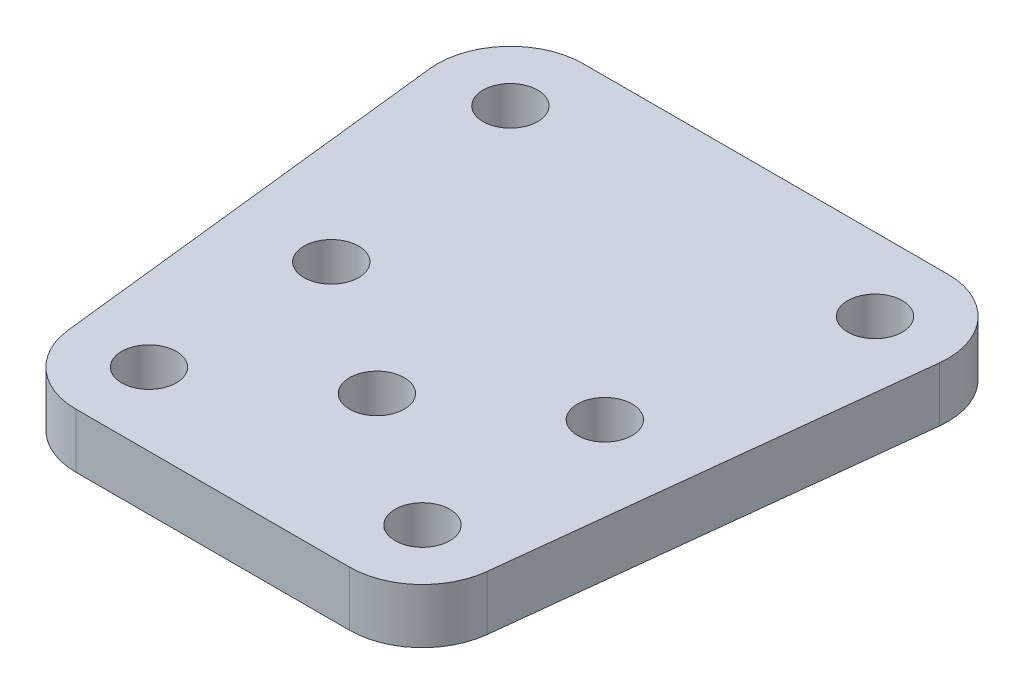
from build123d import *

# Parameters (mm, degrees)
SKETCH1_R           = 1.5
BOSS_EXTRUDE1_DEPTH = 3


with BuildPart() as part:
    # Sketch1 → Boss-Extrude1 (new body)
    with BuildSketch(Plane(origin=(0, 0, 0), x_dir=(1, 0, 0), z_dir=(0, 1, 0))):
        with BuildLine():
            Line((-10.458743839, 9.337820174), (-7.958743839, -12.982687901))
            ThreePointArc((-7.958743839, -12.982687901), (-6.649970685, -15.519142393), (-3.983600283, -16.537453462))
            Line((-3.983600283, -16.537453462), (11.016399717, -16.537453462))
            ThreePointArc((11.016399717, -16.537453462), (13.68277012, -15.519142393), (14.991543274, -12.982687901))
            Line((14.991543274, -12.982687901), (17.491543274, 9.337820174))
            ThreePointArc((17.491543274, 9.337820174), (16.498088648, 12.449425016), (13.516399717, 13.783054613))
            Line((13.516399717, 13.783054613), (-6.483600283, 13.783054613))
            ThreePointArc((-6.483600283, 13.783054613), (-9.465289213, 12.449425016), (-10.458743839, 9.337820174))
        make_face()
        with Locations((-3.983600283, -12.537453462)):
            Circle(SKETCH1_R, mode=Mode.SUBTRACT)
        with Locations((11.016399717, -12.537453462)):
            Circle(SKETCH1_R, mode=Mode.SUBTRACT)
        with Locations((3.516399717, -7.537453462)):
            Circle(SKETCH1_R, mode=Mode.SUBTRACT)
        with Locations((11.016399717, -2.537453462)):
            Circle(SKETCH1_R, mode=Mode.SUBTRACT)
        with Locations((-3.983600283, -2.537453462)):
            Circle(SKETCH1_R, mode=Mode.SUBTRACT)
        with Locations((13.516399717, 9.783054613)):
            Circle(SKETCH1_R, mode=Mode.SUBTRACT)
        with Locations((-6.483600283, 9.783054613)):
            Circle(SKETCH1_R, mode=Mode.SUBTRACT)
    extrude(amount=BOSS_EXTRUDE1_DEPTH)


solid = part.part
